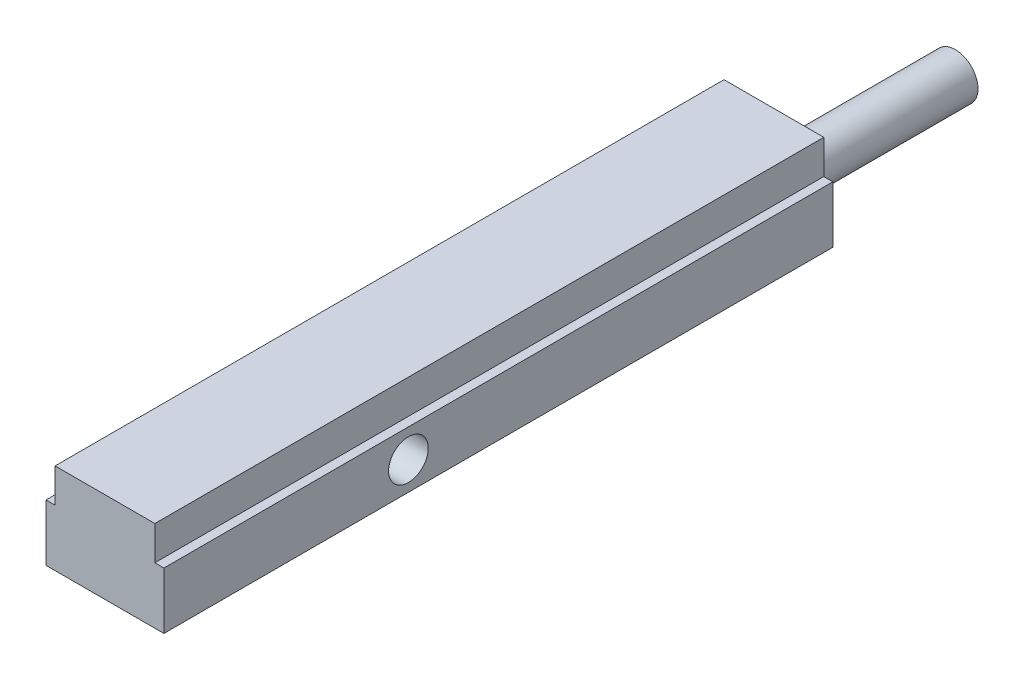
from build123d import *

# Parameters (mm, degrees)
BOSS_EXTRUDE1_DEPTH          = 295
SKETCH3_R                    = 10
BOSS_EXTRUDE3_DEPTH          = 80
M20_TAPPED_HOLE1_D           = 17.5
M20_TAPPED_HOLE1_CSINK_D     = 20.05
M20_TAPPED_HOLE1_CSINK_ANGLE = 90


with BuildPart() as part:
    # Sketch1 → Boss-Extrude1 (new body)
    with BuildSketch(Plane.XY):
        Polygon((-26, -12.5), (26, -12.5), (26, 12.5), (22, 12.5), (22, 27.5), (-22, 27.5), (-22, 12.5), (-26, 12.5), align=None)
    extrude(amount=BOSS_EXTRUDE1_DEPTH)

    # Sketch3 → Boss-Extrude3 (add)
    with BuildSketch(Plane.XY):
        Circle(SKETCH3_R)
    extrude(amount=-BOSS_EXTRUDE3_DEPTH)

    # M20 Tapped Hole1 (through all)
    with Locations(Plane.ZY.offset(26)):
        with Locations((187.17, 0)):
            CounterSinkHole(M20_TAPPED_HOLE1_D / 2, M20_TAPPED_HOLE1_CSINK_D / 2, counter_sink_angle=M20_TAPPED_HOLE1_CSINK_ANGLE)


solid = part.part
